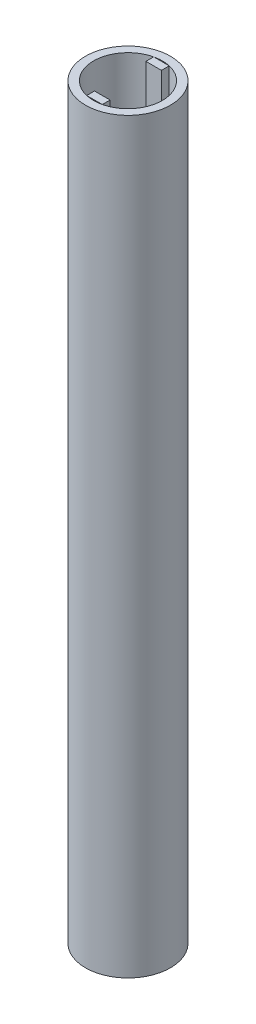
from build123d import *

# Parameters (mm, degrees)
SKETCH1_R           = 34.6583
SKETCH1_R_2         = 28.0416
BOSS_EXTRUDE1_DEPTH = 609.6
SKETCH3_W           = 12.7
SKETCH3_H           = 6.35
BOSS_EXTRUDE3_DEPTH = 127
CUT_EXTRUDE2_DEPTH  = 6.35
CIRPATTERN8_COUNT   = 2


with BuildPart() as part:
    # Sketch1 → Boss-Extrude1 (new body)
    with BuildSketch(Plane(origin=(0, 0, 0), x_dir=(1, 0, 0), z_dir=(0, 1, 0))):
        Circle(SKETCH1_R)
        Circle(SKETCH1_R_2, mode=Mode.SUBTRACT)
    extrude(amount=BOSS_EXTRUDE1_DEPTH)


with BuildPart() as body_2:
    # Sketch3 → Boss-Extrude3 (new body)
    with BuildSketch(Plane(origin=(0, 609.6, 0), x_dir=(1, 0, 0), z_dir=(0, 1, 0))):
        with Locations((0, 24.138162222)):
            Rectangle(SKETCH3_W, SKETCH3_H)
    extrude(amount=-BOSS_EXTRUDE3_DEPTH)

    # Sketch4 → Cut-Extrude2 (cut)
    with BuildSketch(Plane.XY.offset(-20.963162222)):
        Polygon((6.35, 482.6), (-6.35, 482.6), (-6.35, 495.3), align=None)
    extrude(amount=-CUT_EXTRUDE2_DEPTH, mode=Mode.SUBTRACT)


with BuildPart() as cirpattern8_1:
    # CirPattern8: pattern copy
    add(body_2.part.rotate(Axis((0, 0, 0), (0, 1, 0)), 1 * 360 / CIRPATTERN8_COUNT))


solid = Compound([part.part, body_2.part, cirpattern8_1.part])
